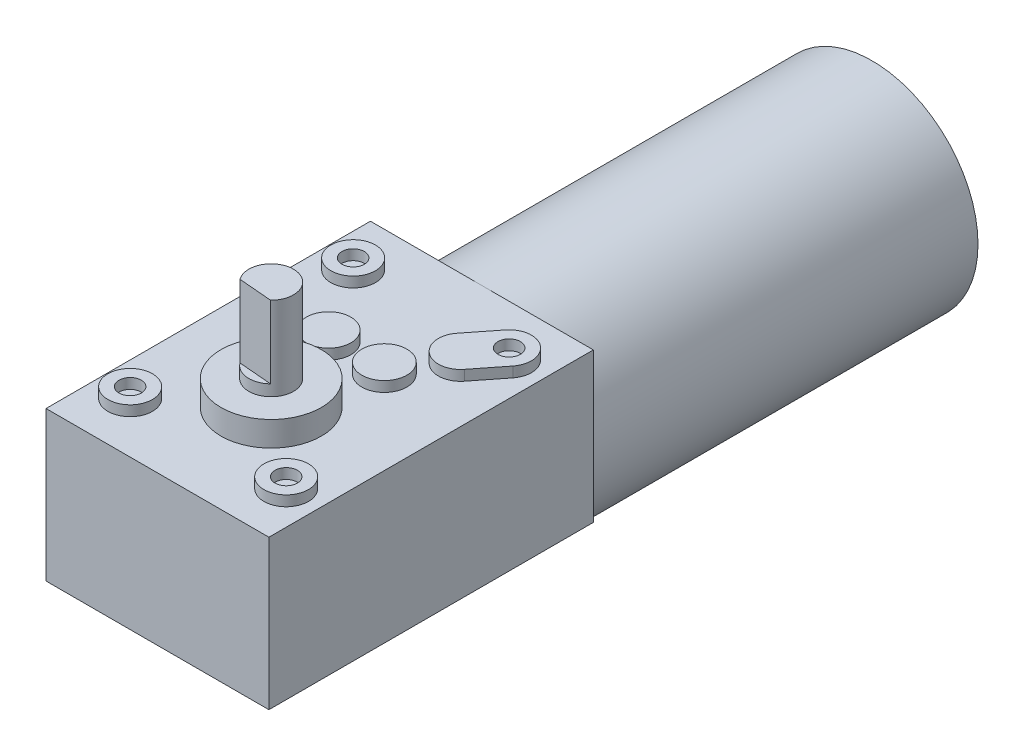
from build123d import *

# Parameters (mm, degrees)
SKETCH_1_R                = 19
EXTRUDE_424_DEPTH         = 70
SKETCH_2_W                = 39.990162
SKETCH_2_H                = 26.804556
EXTRUDE_710_DEPTH         = 58.2
SKETCH_3_R                = 4
SKETCH_3_R_2              = 2
EXTRUDE_1264_DEPTH        = 1.85
EXTRUDE_1264_DEPTH_BACK   = 28.65
EXTRUDE_1264_2_DEPTH      = 1.85
EXTRUDE_1264_2_DEPTH_BACK = 28.65
EXTRUDE_1264_3_DEPTH      = 1.85
EXTRUDE_1264_3_DEPTH_BACK = 28.65
SKETCH_3_R_3              = 9
EXTRUDE_1264_4_DEPTH      = 1.85
EXTRUDE_1264_4_DEPTH_BACK = 28.65
SKETCH_3_R_4              = 4.049995
EXTRUDE_1264_5_DEPTH      = 1.85
EXTRUDE_1264_5_DEPTH_BACK = 28.65
EXTRUDE_1264_6_DEPTH      = 1.85
EXTRUDE_1264_6_DEPTH_BACK = 28.65
EXTRUDE_1264_7_DEPTH      = 1.85
EXTRUDE_1264_7_DEPTH_BACK = 28.65
SKETCH_5_R                = 9
EXTRUDE_1445_DEPTH        = 2.6
EXTRUDE_1445_DEPTH_BACK   = 33.1
SKETCH_6_R                = 4
EXTRUDE_1548_DEPTH        = 2
EXTRUDE_D_DEPTH           = 13


with BuildPart() as part:
    # 草图1 → Extrude 424 (new body)
    with BuildSketch(Plane.XY):
        Circle(SKETCH_1_R)
    extrude(amount=EXTRUDE_424_DEPTH)

    # 草图2 → Extrude 710 (add)
    with BuildSketch(Plane.XY.offset(70)):
        with Locations((0, 5.665)):
            Rectangle(SKETCH_2_W, SKETCH_2_H)
    extrude(amount=EXTRUDE_710_DEPTH)



with BuildPart() as body_2:
    # 草图3 → Extrude 1264 (new body, two sides)
    with BuildSketch(Plane(origin=(0, 19.067278, 0), x_dir=(1, 0, 0), z_dir=(0, 1, 0))) as extrude_1264_sk:
        with Locations((13.995081, -119.1)):
            Circle(SKETCH_3_R)
        with Locations((13.995081, -119.1)):
            Circle(SKETCH_3_R_2, mode=Mode.SUBTRACT)
    extrude(amount=EXTRUDE_1264_DEPTH)
    extrude(extrude_1264_sk.sketch, amount=-EXTRUDE_1264_DEPTH_BACK)


with BuildPart() as body_3:
    # 草图3 → Extrude 1264 2 (new body, two sides)
    with BuildSketch(Plane(origin=(0, 19.067278, 0), x_dir=(1, 0, 0), z_dir=(0, 1, 0))) as extrude_1264_2_sk:
        with Locations((-13.995081, -119.1)):
            Circle(SKETCH_3_R)
        with Locations((-13.995081, -119.1)):
            Circle(SKETCH_3_R_2, mode=Mode.SUBTRACT)
    extrude(amount=EXTRUDE_1264_2_DEPTH)
    extrude(extrude_1264_2_sk.sketch, amount=-EXTRUDE_1264_2_DEPTH_BACK)


with BuildPart() as body_4:
    # 草图3 → Extrude 1264 3 (new body, two sides)
    with BuildSketch(Plane(origin=(0, 19.067278, 0), x_dir=(1, 0, 0), z_dir=(0, 1, 0))) as extrude_1264_3_sk:
        with Locations((-13.995081, -79.1)):
            Circle(SKETCH_3_R)
        with Locations((-13.995081, -79.1)):
            Circle(SKETCH_3_R_2, mode=Mode.SUBTRACT)
    extrude(amount=EXTRUDE_1264_3_DEPTH)
    extrude(extrude_1264_3_sk.sketch, amount=-EXTRUDE_1264_3_DEPTH_BACK)


with BuildPart() as body_5:
    # 草图3 → Extrude 1264 4 (new body, two sides)
    with BuildSketch(Plane(origin=(0, 19.067278, 0), x_dir=(1, 0, 0), z_dir=(0, 1, 0))) as extrude_1264_4_sk:
        with Locations((0, -107.8)):
            Circle(SKETCH_3_R_3)
    extrude(amount=EXTRUDE_1264_4_DEPTH)
    extrude(extrude_1264_4_sk.sketch, amount=-EXTRUDE_1264_4_DEPTH_BACK)


with BuildPart() as body_6:
    # 草图3 → Extrude 1264 5 (new body, two sides)
    with BuildSketch(Plane(origin=(0, 19.067278, 0), x_dir=(1, 0, 0), z_dir=(0, 1, 0))) as extrude_1264_5_sk:
        with Locations((5, -92.5)):
            Circle(SKETCH_3_R_4)
    extrude(amount=EXTRUDE_1264_5_DEPTH)
    extrude(extrude_1264_5_sk.sketch, amount=-EXTRUDE_1264_5_DEPTH_BACK)


with BuildPart() as body_7:
    # 草图3 → Extrude 1264 6 (new body, two sides)
    with BuildSketch(Plane(origin=(0, 19.067278, 0), x_dir=(1, 0, 0), z_dir=(0, 1, 0))) as extrude_1264_6_sk:
        with Locations((-5, -92.5)):
            Circle(SKETCH_3_R)
    extrude(amount=EXTRUDE_1264_6_DEPTH)
    extrude(extrude_1264_6_sk.sketch, amount=-EXTRUDE_1264_6_DEPTH_BACK)


with BuildPart() as body_8:
    # 草图3 → Extrude 1264 7 (new body, two sides)
    with BuildSketch(Plane(origin=(0, 19.067278, 0), x_dir=(1, 0, 0), z_dir=(0, 1, 0))) as extrude_1264_7_sk:
        with BuildLine():
            Line((17.130899, -81.570623), (13.290851, -86.444572))
            ThreePointArc((13.290851, -86.444572), (7.68441, -87.109767), (7.019215, -81.503326))
            Line((7.019215, -81.503326), (10.859262, -76.629377))
            ThreePointArc((10.859262, -76.629377), (16.465704, -75.964182), (17.130899, -81.570623))
        make_face()
        with Locations((13.995081, -79.1)):
            Circle(SKETCH_3_R_2, mode=Mode.SUBTRACT)
    extrude(amount=EXTRUDE_1264_7_DEPTH)
    extrude(extrude_1264_7_sk.sketch, amount=-EXTRUDE_1264_7_DEPTH_BACK)


with BuildPart() as part_1:
    add(part.part)

    add(body_5.part)  # Extrude 1445 merges body 5
    # 草图5 → Extrude 1445 (add, two sides)
    with BuildSketch(Plane(origin=(0, 20.917278, 0), x_dir=(1, 0, 0), z_dir=(0, 1, 0))) as extrude_1445_sk:
        with Locations((0, -107.8)):
            Circle(SKETCH_5_R)
    extrude(amount=EXTRUDE_1445_DEPTH)
    extrude(extrude_1445_sk.sketch, amount=-EXTRUDE_1445_DEPTH_BACK)

    # 草图6 → Extrude 1548 (add)
    with BuildSketch(Plane(origin=(0, 23.517278, 0), x_dir=(1, 0, 0), z_dir=(0, 1, 0))):
        with Locations((0, -107.8)):
            Circle(SKETCH_6_R)
    extrude(amount=EXTRUDE_1548_DEPTH)

    # 草图7 → D型轴 (add)
    with BuildSketch(Plane(origin=(0, 25.517278, 0), x_dir=(1, 0, 0), z_dir=(0, 1, 0))):
        with BuildLine():
            Line((2.772722, -110.683056), (-3.217627, -110.176316))
            ThreePointArc((-3.217627, -110.176316), (0.337167, -103.814236), (2.772722, -110.683056))
        make_face()
    extrude(amount=EXTRUDE_D_DEPTH)


solid = Compound([body_2.part, body_3.part, body_4.part, body_6.part, body_7.part, body_8.part, part_1.part])
